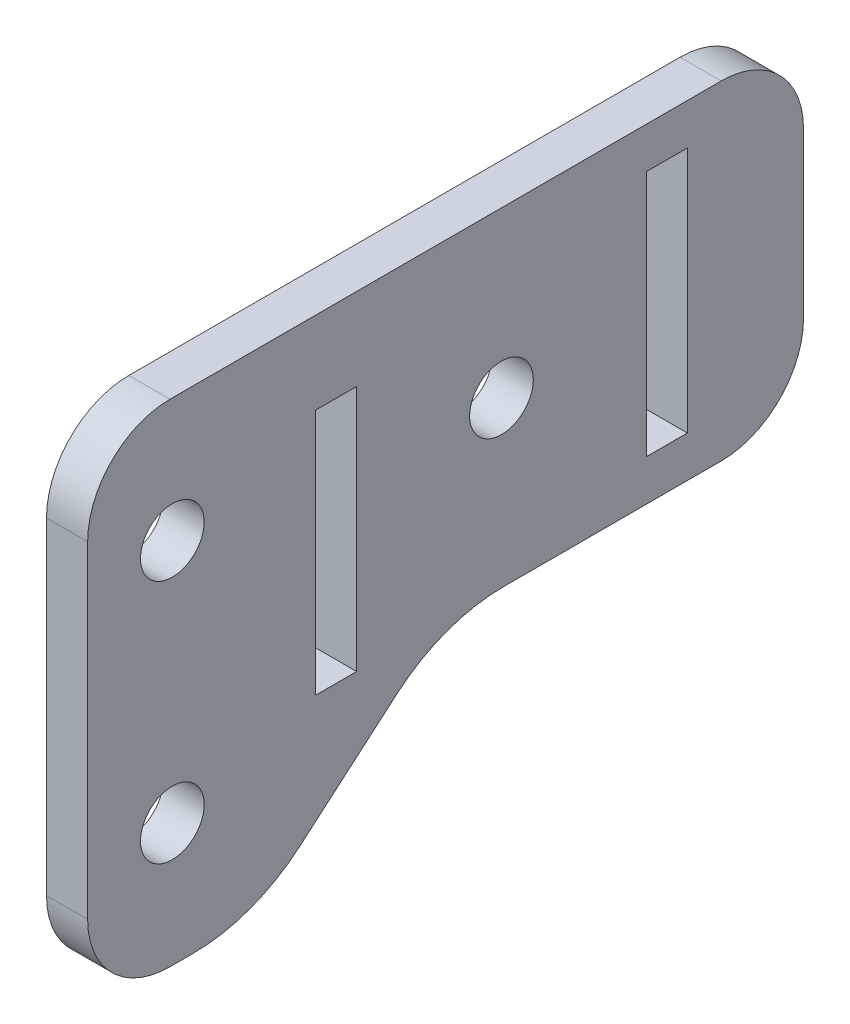
from build123d import *

# Parameters (mm, degrees)
BOSS_EXTRUDE1_DEPTH              = 3.175
SKETCH7_W                        = 3.175
SKETCH7_H                        = 19.05
CUT_EXTRUDE1_DEPTH               = 3.175
F_10_0_1935_DIAMETER_HOLE1_D     = 4.9149
F_10_0_1935_DIAMETER_HOLE1_DEPTH = 9.699415072
F_10_0_1935_DIAMETER_HOLE1_TIP   = 1.476584928
FILLET1_R                        = 6.35


with BuildPart() as part:
    # Sketch1 → Boss-Extrude1 (new body)
    with BuildSketch(Plane(origin=(0, 0, 0), x_dir=(0, 0, -1), z_dir=(1, 0, 0))):
        with BuildLine():
            Line((-31.934860292, 17.215678835), (23.310139708, 17.215678835))
            Line((23.310139708, 17.215678835), (23.310139708, -8.184321165))
            Line((23.310139708, -8.184321165), (0.193463217, -8.184321165))
            ThreePointArc((0.193463217, -8.184321165), (-4.215993747, -8.974380389), (-8.076831475, -11.24625986))
            Line((-8.076831475, -11.24625986), (-15.545168525, -17.65474247))
            ThreePointArc((-15.545168525, -17.65474247), (-19.406006253, -19.926621941), (-23.815463217, -20.716681165))
            Line((-23.815463217, -20.716681165), (-31.934860292, -20.716681165))
            Line((-31.934860292, -20.716681165), (-31.934860292, 17.215678835))
        make_face()
    extrude(amount=BOSS_EXTRUDE1_DEPTH)

    # Sketch7 → Cut-Extrude1 (cut)
    with BuildSketch(Plane.ZY):
        with Locations((-12.7635, 4.515678835)):
            Rectangle(SKETCH7_W, SKETCH7_H)
        with Locations((12.7635, 1.340678835)):
            Rectangle(SKETCH7_W, SKETCH7_H)
    extrude(amount=-CUT_EXTRUDE1_DEPTH, mode=Mode.SUBTRACT)

    # #10 (0.1935) Diameter Hole1
    with Locations(Plane.ZY):
        with Locations((25.4, 7.690678835), (25.4, -11.191681165), (0, 4.515678835)):
            Hole(F_10_0_1935_DIAMETER_HOLE1_D / 2, depth=F_10_0_1935_DIAMETER_HOLE1_DEPTH)
            with Locations((0, 0, -(F_10_0_1935_DIAMETER_HOLE1_DEPTH + F_10_0_1935_DIAMETER_HOLE1_TIP / 2))):  # 118° drill point
                Cone(0, F_10_0_1935_DIAMETER_HOLE1_D / 2, F_10_0_1935_DIAMETER_HOLE1_TIP, mode=Mode.SUBTRACT)

    # Fillet1
    fillet1_edges = [part.edges().sort_by_distance(p)[0] for p in [
        (1.5875, 17.215678835, 31.934860292),
        (1.5875, 17.215678835, -23.310139708),
        (1.5875, -8.184321165, -23.310139708),
        (1.5875, -20.716681165, 31.934860292),
    ]]
    fillet(fillet1_edges, radius=FILLET1_R)


solid = part.part
